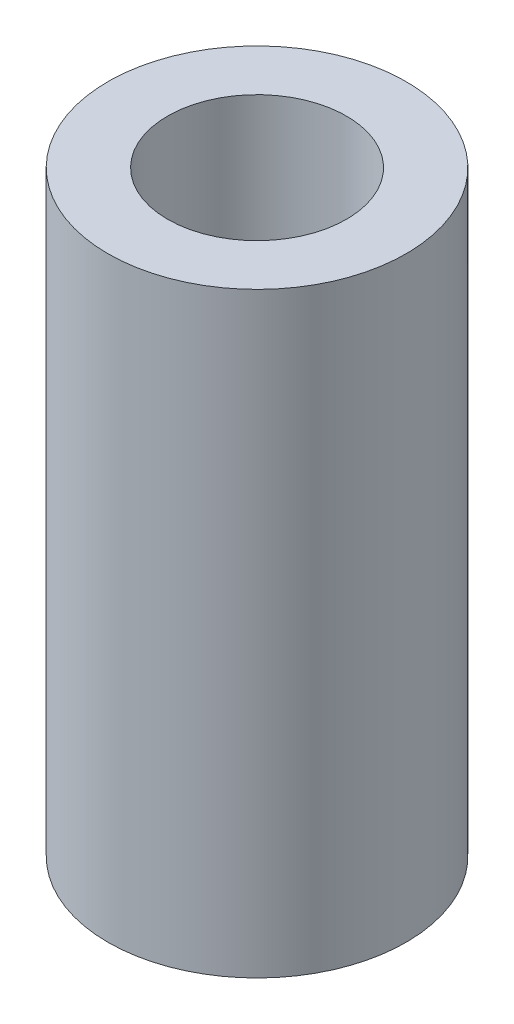
from build123d import *

# Parameters (mm, degrees)
SKETCH1_R           = 6.35
SKETCH1_R_2         = 3.81
BOSS_EXTRUDE1_DEPTH = 25.4


with BuildPart() as part:
    # Sketch1 → Boss-Extrude1 (new body)
    with BuildSketch(Plane(origin=(0, 0, 0), x_dir=(1, 0, 0), z_dir=(0, 1, 0))):
        Circle(SKETCH1_R)
        Circle(SKETCH1_R_2, mode=Mode.SUBTRACT)
    extrude(amount=BOSS_EXTRUDE1_DEPTH)


solid = part.part
